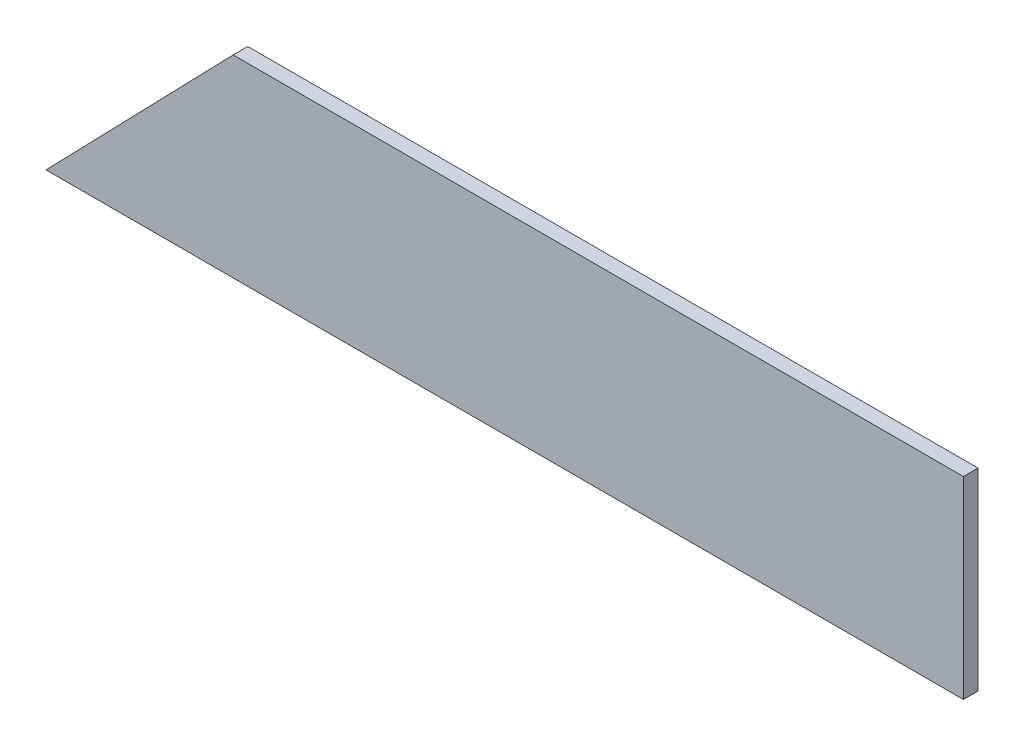
from build123d import *

# Parameters (mm, degrees)
BOSS_EXTRUDE1_DEPTH = 18.25625


with BuildPart() as part:
    # Sketch1 → Boss-Extrude1 (new body)
    with BuildSketch(Plane.XY):
        Polygon((-338.825884956, -50.406637168), (-104.989917187, 190.893362832), (807.349115044, 190.893362832), (807.349115044, -50.406637168), align=None)
    extrude(amount=BOSS_EXTRUDE1_DEPTH)


solid = part.part
